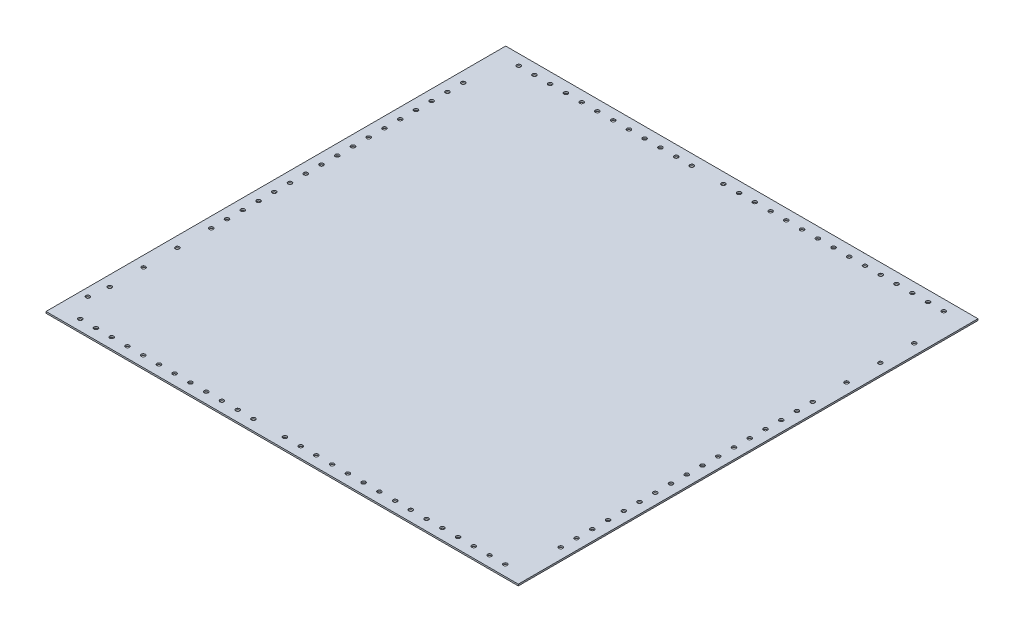
from build123d import *

# Parameters (mm, degrees)
SKETCH1_W                          = 600
SKETCH1_H                          = 584
BOSS_EXTRUDE1_DEPTH                = 2.032
F_5_0_5_DIAMETER_HOLE2_AT_2_COUNT  = 2
F_5_0_5_DIAMETER_HOLE2_AT_2_PITCH  = 724.393414567
F_5_0_5_DIAMETER_HOLE2_AT_3_COUNT  = 2
F_5_0_5_DIAMETER_HOLE2_AT_3_PITCH  = 712.134229611
F_5_0_5_DIAMETER_HOLE2_AT_4_COUNT  = 2
F_5_0_5_DIAMETER_HOLE2_AT_4_PITCH  = 700.231749422
F_5_0_5_DIAMETER_HOLE2_AT_5_COUNT  = 2
F_5_0_5_DIAMETER_HOLE2_AT_5_PITCH  = 688.704468415
F_5_0_5_DIAMETER_HOLE2_AT_6_COUNT  = 2
F_5_0_5_DIAMETER_HOLE2_AT_6_PITCH  = 677.571536245
F_5_0_5_DIAMETER_HOLE2_AT_7_COUNT  = 2
F_5_0_5_DIAMETER_HOLE2_AT_7_PITCH  = 666.85270386
F_5_0_5_DIAMETER_HOLE2_AT_8_COUNT  = 2
F_5_0_5_DIAMETER_HOLE2_AT_8_PITCH  = 656.568252781
F_5_0_5_DIAMETER_HOLE2_AT_9_COUNT  = 2
F_5_0_5_DIAMETER_HOLE2_AT_9_PITCH  = 646.738905955
F_5_0_5_DIAMETER_HOLE2_AT_10_COUNT = 2
F_5_0_5_DIAMETER_HOLE2_AT_10_PITCH = 637.385718691
F_5_0_5_DIAMETER_HOLE2_AT_11_COUNT = 2
F_5_0_5_DIAMETER_HOLE2_AT_11_PITCH = 628.529948616
F_5_0_5_DIAMETER_HOLE2_AT_12_COUNT = 2
F_5_0_5_DIAMETER_HOLE2_AT_12_PITCH = 620.192904041
F_5_0_5_DIAMETER_HOLE2_AT_13_COUNT = 2
F_5_0_5_DIAMETER_HOLE2_AT_13_PITCH = 612.395770836
F_5_0_5_DIAMETER_HOLE2_AT_14_COUNT = 2
F_5_0_5_DIAMETER_HOLE2_AT_14_PITCH = 598.504188764
F_5_0_5_DIAMETER_HOLE2_AT_15_COUNT = 2
F_5_0_5_DIAMETER_HOLE2_AT_15_PITCH = 592.449665275
F_5_0_5_DIAMETER_HOLE2_AT_16_COUNT = 2
F_5_0_5_DIAMETER_HOLE2_AT_16_PITCH = 587.014435767
F_5_0_5_DIAMETER_HOLE2_AT_17_COUNT = 2
F_5_0_5_DIAMETER_HOLE2_AT_17_PITCH = 582.21584461
F_5_0_5_DIAMETER_HOLE2_AT_18_COUNT = 2
F_5_0_5_DIAMETER_HOLE2_AT_18_PITCH = 578.069746337
F_5_0_5_DIAMETER_HOLE2_AT_19_COUNT = 2
F_5_0_5_DIAMETER_HOLE2_AT_19_PITCH = 574.590265794
F_5_0_5_DIAMETER_HOLE2_AT_20_COUNT = 2
F_5_0_5_DIAMETER_HOLE2_AT_20_PITCH = 571.789572711
F_5_0_5_DIAMETER_HOLE2_AT_21_COUNT = 2
F_5_0_5_DIAMETER_HOLE2_AT_21_PITCH = 569.677678496
F_5_0_5_DIAMETER_HOLE2_AT_22_COUNT = 2
F_5_0_5_DIAMETER_HOLE2_AT_22_PITCH = 568.262262773
F_5_0_5_DIAMETER_HOLE2_AT_23_COUNT = 2
F_5_0_5_DIAMETER_HOLE2_AT_23_PITCH = 567.548536433
F_5_0_5_DIAMETER_HOLE2_AT_24_COUNT = 2
F_5_0_5_DIAMETER_HOLE2_AT_24_PITCH = 567.539146776
F_5_0_5_DIAMETER_HOLE2_AT_25_COUNT = 2
F_5_0_5_DIAMETER_HOLE2_AT_25_PITCH = 568.234128716
F_5_0_5_DIAMETER_HOLE2_AT_26_COUNT = 2
F_5_0_5_DIAMETER_HOLE2_AT_26_PITCH = 569.630904142
F_5_0_5_DIAMETER_HOLE2_AT_27_COUNT = 2
F_5_0_5_DIAMETER_HOLE2_AT_27_PITCH = 571.724329436
F_5_0_5_DIAMETER_HOLE2_AT_28_COUNT = 2
F_5_0_5_DIAMETER_HOLE2_AT_28_PITCH = 574.506789154
F_5_0_5_DIAMETER_HOLE2_AT_29_COUNT = 2
F_5_0_5_DIAMETER_HOLE2_AT_29_PITCH = 630.477451441
F_5_0_5_DIAMETER_HOLE2_AT_30_COUNT = 2
F_5_0_5_DIAMETER_HOLE2_AT_30_PITCH = 650.2001951
F_5_0_5_DIAMETER_HOLE2_AT_31_COUNT = 2
F_5_0_5_DIAMETER_HOLE2_AT_31_PITCH = 669.939378332
F_5_0_5_DIAMETER_HOLE2_AT_32_COUNT = 2
F_5_0_5_DIAMETER_HOLE2_AT_32_PITCH = 689.693589627
F_5_0_5_DIAMETER_HOLE2_AT_33_COUNT = 2
F_5_0_5_DIAMETER_HOLE2_AT_33_PITCH = 709.461573663
F_5_0_5_DIAMETER_HOLE2_AT_34_COUNT = 2
F_5_0_5_DIAMETER_HOLE2_AT_34_PITCH = 729.242210405
F_5_0_5_DIAMETER_HOLE2_AT_35_COUNT = 2
F_5_0_5_DIAMETER_HOLE2_AT_35_PITCH = 749.034497449
F_5_0_5_DIAMETER_HOLE2_AT_36_COUNT = 2
F_5_0_5_DIAMETER_HOLE2_AT_36_PITCH = 768.83753505
F_5_0_5_DIAMETER_HOLE2_AT_37_COUNT = 2
F_5_0_5_DIAMETER_HOLE2_AT_37_PITCH = 788.650513367
F_5_0_5_DIAMETER_HOLE2_AT_38_COUNT = 2
F_5_0_5_DIAMETER_HOLE2_AT_38_PITCH = 808.472701559
F_5_0_5_DIAMETER_HOLE2_AT_39_COUNT = 2
F_5_0_5_DIAMETER_HOLE2_AT_39_PITCH = 828.30343842
F_5_0_5_DIAMETER_HOLE2_AT_40_COUNT = 2
F_5_0_5_DIAMETER_HOLE2_AT_40_PITCH = 848.142124311
F_5_0_5_DIAMETER_HOLE2_AT_41_COUNT = 2
F_5_0_5_DIAMETER_HOLE2_AT_41_PITCH = 867.988214184
F_5_0_5_DIAMETER_HOLE2_AT_42_COUNT = 2
F_5_0_5_DIAMETER_HOLE2_AT_42_PITCH = 887.841211532
F_5_0_5_DIAMETER_HOLE2_AT_43_COUNT = 2
F_5_0_5_DIAMETER_HOLE2_AT_43_PITCH = 907.700663119
F_5_0_5_DIAMETER_HOLE2_AT_44_COUNT = 2
F_5_0_5_DIAMETER_HOLE2_AT_44_PITCH = 927.566154384
F_5_0_5_DIAMETER_HOLE2_AT_45_COUNT = 2
F_5_0_5_DIAMETER_HOLE2_AT_45_PITCH = 947.437305415
F_5_0_5_DIAMETER_HOLE2_AT_46_COUNT = 2
F_5_0_5_DIAMETER_HOLE2_AT_46_PITCH = 990.177849225
F_5_0_5_DIAMETER_HOLE2_AT_47_COUNT = 2
F_5_0_5_DIAMETER_HOLE2_AT_47_PITCH = 1032.939929764
F_5_0_5_DIAMETER_HOLE2_AT_48_COUNT = 2
F_5_0_5_DIAMETER_HOLE2_AT_48_PITCH = 1075.720978649
F_5_0_5_DIAMETER_HOLE2_AT_49_COUNT = 2
F_5_0_5_DIAMETER_HOLE2_AT_49_PITCH = 1128.042899183
F_5_0_5_DIAMETER_HOLE2_AT_50_COUNT = 2
F_5_0_5_DIAMETER_HOLE2_AT_50_PITCH = 1126.628350647
F_5_0_5_DIAMETER_HOLE2_AT_51_COUNT = 2
F_5_0_5_DIAMETER_HOLE2_AT_51_PITCH = 1125.567456248
F_5_0_5_DIAMETER_HOLE2_AT_52_COUNT = 2
F_5_0_5_DIAMETER_HOLE2_AT_52_PITCH = 1124.861216618
F_5_0_5_DIAMETER_HOLE2_AT_53_COUNT = 2
F_5_0_5_DIAMETER_HOLE2_AT_53_PITCH = 1124.510299968
F_5_0_5_DIAMETER_HOLE2_AT_54_COUNT = 2
F_5_0_5_DIAMETER_HOLE2_AT_54_PITCH = 1124.515038948
F_5_0_5_DIAMETER_HOLE2_AT_55_COUNT = 2
F_5_0_5_DIAMETER_HOLE2_AT_55_PITCH = 1124.87542906
F_5_0_5_DIAMETER_HOLE2_AT_56_COUNT = 2
F_5_0_5_DIAMETER_HOLE2_AT_56_PITCH = 1126.661460721
F_5_0_5_DIAMETER_HOLE2_AT_57_COUNT = 2
F_5_0_5_DIAMETER_HOLE2_AT_57_PITCH = 1125.591128691
F_5_0_5_DIAMETER_HOLE2_AT_58_COUNT = 2
F_5_0_5_DIAMETER_HOLE2_AT_58_PITCH = 1128.085415719
F_5_0_5_DIAMETER_HOLE2_AT_59_COUNT = 2
F_5_0_5_DIAMETER_HOLE2_AT_59_PITCH = 1129.861656683
F_5_0_5_DIAMETER_HOLE2_AT_60_COUNT = 2
F_5_0_5_DIAMETER_HOLE2_AT_60_PITCH = 1131.988525263
F_5_0_5_DIAMETER_HOLE2_AT_61_COUNT = 2
F_5_0_5_DIAMETER_HOLE2_AT_61_PITCH = 1134.464049413
F_5_0_5_DIAMETER_HOLE2_AT_62_COUNT = 2
F_5_0_5_DIAMETER_HOLE2_AT_62_PITCH = 1137.285952387
F_5_0_5_DIAMETER_HOLE2_AT_63_COUNT = 2
F_5_0_5_DIAMETER_HOLE2_AT_63_PITCH = 1140.451662974
F_5_0_5_DIAMETER_HOLE2_AT_64_COUNT = 2
F_5_0_5_DIAMETER_HOLE2_AT_64_PITCH = 1147.802819194
F_5_0_5_DIAMETER_HOLE2_AT_65_COUNT = 2
F_5_0_5_DIAMETER_HOLE2_AT_65_PITCH = 1156.491516579
F_5_0_5_DIAMETER_HOLE2_AT_66_COUNT = 2
F_5_0_5_DIAMETER_HOLE2_AT_66_PITCH = 1151.981757596
F_5_0_5_DIAMETER_HOLE2_AT_67_COUNT = 2
F_5_0_5_DIAMETER_HOLE2_AT_67_PITCH = 1161.328242145
F_5_0_5_DIAMETER_HOLE2_AT_68_COUNT = 2
F_5_0_5_DIAMETER_HOLE2_AT_68_PITCH = 1166.487867098
F_5_0_5_DIAMETER_HOLE2_AT_69_COUNT = 2
F_5_0_5_DIAMETER_HOLE2_AT_69_PITCH = 1171.966126717
F_5_0_5_DIAMETER_HOLE2_AT_70_COUNT = 2
F_5_0_5_DIAMETER_HOLE2_AT_70_PITCH = 1177.758574691
F_5_0_5_DIAMETER_HOLE2_AT_71_COUNT = 2
F_5_0_5_DIAMETER_HOLE2_AT_71_PITCH = 1183.860599201
F_5_0_5_DIAMETER_HOLE2_AT_72_COUNT = 2
F_5_0_5_DIAMETER_HOLE2_AT_72_PITCH = 1190.267439035
F_5_0_5_DIAMETER_HOLE2_AT_73_COUNT = 2
F_5_0_5_DIAMETER_HOLE2_AT_73_PITCH = 1196.974199601
F_5_0_5_DIAMETER_HOLE2_AT_74_COUNT = 2
F_5_0_5_DIAMETER_HOLE2_AT_74_PITCH = 1203.975868776
F_5_0_5_DIAMETER_HOLE2_AT_75_COUNT = 2
F_5_0_5_DIAMETER_HOLE2_AT_75_PITCH = 1211.267332458
F_5_0_5_DIAMETER_HOLE3_AT_2_COUNT  = 2
F_5_0_5_DIAMETER_HOLE3_AT_2_PITCH  = 20
F_5_0_5_DIAMETER_HOLE3_AT_3_COUNT  = 2
F_5_0_5_DIAMETER_HOLE3_AT_3_PITCH  = 40
F_5_0_5_DIAMETER_HOLE3_AT_4_COUNT  = 2
F_5_0_5_DIAMETER_HOLE3_AT_4_PITCH  = 60
F_5_0_5_DIAMETER_HOLE3_AT_5_COUNT  = 2
F_5_0_5_DIAMETER_HOLE3_AT_5_PITCH  = 80
F_5_0_5_DIAMETER_HOLE3_AT_6_COUNT  = 2
F_5_0_5_DIAMETER_HOLE3_AT_6_PITCH  = 100
F_5_0_5_DIAMETER_HOLE3_AT_7_COUNT  = 2
F_5_0_5_DIAMETER_HOLE3_AT_7_PITCH  = 120
F_5_0_5_DIAMETER_HOLE3_AT_8_COUNT  = 2
F_5_0_5_DIAMETER_HOLE3_AT_8_PITCH  = 140
F_5_0_5_DIAMETER_HOLE3_AT_9_COUNT  = 2
F_5_0_5_DIAMETER_HOLE3_AT_9_PITCH  = 160
F_5_0_5_DIAMETER_HOLE3_AT_10_COUNT = 2
F_5_0_5_DIAMETER_HOLE3_AT_10_PITCH = 180
F_5_0_5_DIAMETER_HOLE3_AT_11_COUNT = 2
F_5_0_5_DIAMETER_HOLE3_AT_11_PITCH = 200
F_5_0_5_DIAMETER_HOLE3_AT_12_COUNT = 2
F_5_0_5_DIAMETER_HOLE3_AT_12_PITCH = 220
F_5_0_5_DIAMETER_HOLE3_AT_13_COUNT = 2
F_5_0_5_DIAMETER_HOLE3_AT_13_PITCH = 240
F_5_0_5_DIAMETER_HOLE3_AT_14_COUNT = 2
F_5_0_5_DIAMETER_HOLE3_AT_14_PITCH = 260
F_5_0_5_DIAMETER_HOLE3_AT_15_COUNT = 2
F_5_0_5_DIAMETER_HOLE3_AT_15_PITCH = 280
F_5_0_5_DIAMETER_HOLE3_AT_16_COUNT = 2
F_5_0_5_DIAMETER_HOLE3_AT_16_PITCH = 300
F_5_0_5_DIAMETER_HOLE3_AT_17_COUNT = 2
F_5_0_5_DIAMETER_HOLE3_AT_17_PITCH = 320
F_5_0_5_DIAMETER_HOLE3_AT_18_COUNT = 2
F_5_0_5_DIAMETER_HOLE3_AT_18_PITCH = 363
F_5_0_5_DIAMETER_HOLE3_AT_19_COUNT = 2
F_5_0_5_DIAMETER_HOLE3_AT_19_PITCH = 406
F_5_0_5_DIAMETER_HOLE3_AT_20_COUNT = 2
F_5_0_5_DIAMETER_HOLE3_AT_20_PITCH = 449
F_5_0_5_DIAMETER_HOLE3_AT_21_COUNT = 2
F_5_0_5_DIAMETER_HOLE3_AT_21_PITCH = 473.647761944


with BuildPart() as part:
    # Sketch1 → Boss-Extrude1 (new body)
    with BuildSketch(Plane(origin=(0, 0, 0), x_dir=(1, 0, 0), z_dir=(0, 1, 0))):
        with Locations((300, 292)):
            Rectangle(SKETCH1_W, SKETCH1_H)
    extrude(amount=BOSS_EXTRUDE1_DEPTH)

    # Sketch2 → Ø5.0 (5) Diameter Hole2 (revolve, cut)
    with BuildSketch(Plane(origin=(480.266452114, 2.032, 553.961923307), x_dir=(0, 0, 1), z_dir=(1, 0, 0))):
        Polygon((0, 0), (0, 2.032), (2.5, 2.032), (2.5, 0.020977491), (2.525, 0), align=None)
    f_5_0_5_diameter_hole2 = revolve(axis=Axis((480.266452114, 8.382, 553.961923307), (0, -1, 0)), mode=Mode.SUBTRACT)

    # Ø5.0 (5) Diameter Hole2 at 2: Ø5.0 (5) Diameter Hole2 ×2
    with Locations(*[Vector(-0.62157723, 0, -0.783352888) * (i * F_5_0_5_DIAMETER_HOLE2_AT_2_PITCH) for i in range(1, F_5_0_5_DIAMETER_HOLE2_AT_2_COUNT)]):
        add(f_5_0_5_diameter_hole2, mode=Mode.SUBTRACT)

    # Ø5.0 (5) Diameter Hole2 at 3: Ø5.0 (5) Diameter Hole2 ×2
    with Locations(*[Vector(-0.604192909, 0, -0.796838082) * (i * F_5_0_5_DIAMETER_HOLE2_AT_3_PITCH) for i in range(1, F_5_0_5_DIAMETER_HOLE2_AT_3_COUNT)]):
        add(f_5_0_5_diameter_hole2, mode=Mode.SUBTRACT)

    # Ø5.0 (5) Diameter Hole2 at 4: Ø5.0 (5) Diameter Hole2 ×2
    with Locations(*[Vector(-0.585900957, 0, -0.810382668) * (i * F_5_0_5_DIAMETER_HOLE2_AT_4_PITCH) for i in range(1, F_5_0_5_DIAMETER_HOLE2_AT_4_COUNT)]):
        add(f_5_0_5_diameter_hole2, mode=Mode.SUBTRACT)

    # Ø5.0 (5) Diameter Hole2 at 5: Ø5.0 (5) Diameter Hole2 ×2
    with Locations(*[Vector(-0.566667519, 0, -0.823946554) * (i * F_5_0_5_DIAMETER_HOLE2_AT_5_PITCH) for i in range(1, F_5_0_5_DIAMETER_HOLE2_AT_5_COUNT)]):
        add(f_5_0_5_diameter_hole2, mode=Mode.SUBTRACT)

    # Ø5.0 (5) Diameter Hole2 at 6: Ø5.0 (5) Diameter Hole2 ×2
    with Locations(*[Vector(-0.546461048, 0, -0.837484521) * (i * F_5_0_5_DIAMETER_HOLE2_AT_6_PITCH) for i in range(1, F_5_0_5_DIAMETER_HOLE2_AT_6_COUNT)]):
        add(f_5_0_5_diameter_hole2, mode=Mode.SUBTRACT)

    # Ø5.0 (5) Diameter Hole2 at 7: Ø5.0 (5) Diameter Hole2 ×2
    with Locations(*[Vector(-0.525253103, 0, -0.850946049) * (i * F_5_0_5_DIAMETER_HOLE2_AT_7_PITCH) for i in range(1, F_5_0_5_DIAMETER_HOLE2_AT_7_COUNT)]):
        add(f_5_0_5_diameter_hole2, mode=Mode.SUBTRACT)

    # Ø5.0 (5) Diameter Hole2 at 8: Ø5.0 (5) Diameter Hole2 ×2
    with Locations(*[Vector(-0.503019223, 0, -0.864275223) * (i * F_5_0_5_DIAMETER_HOLE2_AT_8_PITCH) for i in range(1, F_5_0_5_DIAMETER_HOLE2_AT_8_COUNT)]):
        add(f_5_0_5_diameter_hole2, mode=Mode.SUBTRACT)

    # Ø5.0 (5) Diameter Hole2 at 9: Ø5.0 (5) Diameter Hole2 ×2
    with Locations(*[Vector(-0.479739891, 0, -0.877410757) * (i * F_5_0_5_DIAMETER_HOLE2_AT_9_PITCH) for i in range(1, F_5_0_5_DIAMETER_HOLE2_AT_9_COUNT)]):
        add(f_5_0_5_diameter_hole2, mode=Mode.SUBTRACT)

    # Ø5.0 (5) Diameter Hole2 at 10: Ø5.0 (5) Diameter Hole2 ×2
    with Locations(*[Vector(-0.455401562, 0, -0.890286143) * (i * F_5_0_5_DIAMETER_HOLE2_AT_10_PITCH) for i in range(1, F_5_0_5_DIAMETER_HOLE2_AT_10_COUNT)]):
        add(f_5_0_5_diameter_hole2, mode=Mode.SUBTRACT)

    # Ø5.0 (5) Diameter Hole2 at 11: Ø5.0 (5) Diameter Hole2 ×2
    with Locations(*[Vector(-0.429997732, 0, -0.902829968) * (i * F_5_0_5_DIAMETER_HOLE2_AT_11_PITCH) for i in range(1, F_5_0_5_DIAMETER_HOLE2_AT_11_COUNT)]):
        add(f_5_0_5_diameter_hole2, mode=Mode.SUBTRACT)

    # Ø5.0 (5) Diameter Hole2 at 12: Ø5.0 (5) Diameter Hole2 ×2
    with Locations(*[Vector(-0.403530015, 0, -0.914966407) * (i * F_5_0_5_DIAMETER_HOLE2_AT_12_PITCH) for i in range(1, F_5_0_5_DIAMETER_HOLE2_AT_12_COUNT)]):
        add(f_5_0_5_diameter_hole2, mode=Mode.SUBTRACT)

    # Ø5.0 (5) Diameter Hole2 at 13: Ø5.0 (5) Diameter Hole2 ×2
    with Locations(*[Vector(-0.376009213, 0, -0.926615924) * (i * F_5_0_5_DIAMETER_HOLE2_AT_13_PITCH) for i in range(1, F_5_0_5_DIAMETER_HOLE2_AT_13_COUNT)]):
        add(f_5_0_5_diameter_hole2, mode=Mode.SUBTRACT)

    # Ø5.0 (5) Diameter Hole2 at 14: Ø5.0 (5) Diameter Hole2 ×2
    with Locations(*[Vector(-0.317903292, 0, -0.948123144) * (i * F_5_0_5_DIAMETER_HOLE2_AT_14_PITCH) for i in range(1, F_5_0_5_DIAMETER_HOLE2_AT_14_COUNT)]):
        add(f_5_0_5_diameter_hole2, mode=Mode.SUBTRACT)

    # Ø5.0 (5) Diameter Hole2 at 15: Ø5.0 (5) Diameter Hole2 ×2
    with Locations(*[Vector(-0.287393954, 0, -0.957812463) * (i * F_5_0_5_DIAMETER_HOLE2_AT_15_PITCH) for i in range(1, F_5_0_5_DIAMETER_HOLE2_AT_15_COUNT)]):
        add(f_5_0_5_diameter_hole2, mode=Mode.SUBTRACT)

    # Ø5.0 (5) Diameter Hole2 at 16: Ø5.0 (5) Diameter Hole2 ×2
    with Locations(*[Vector(-0.255984253, 0, -0.966680951) * (i * F_5_0_5_DIAMETER_HOLE2_AT_16_PITCH) for i in range(1, F_5_0_5_DIAMETER_HOLE2_AT_16_COUNT)]):
        add(f_5_0_5_diameter_hole2, mode=Mode.SUBTRACT)

    # Ø5.0 (5) Diameter Hole2 at 17: Ø5.0 (5) Diameter Hole2 ×2
    with Locations(*[Vector(-0.22374254, 0, -0.974648283) * (i * F_5_0_5_DIAMETER_HOLE2_AT_17_PITCH) for i in range(1, F_5_0_5_DIAMETER_HOLE2_AT_17_COUNT)]):
        add(f_5_0_5_diameter_hole2, mode=Mode.SUBTRACT)

    # Ø5.0 (5) Diameter Hole2 at 18: Ø5.0 (5) Diameter Hole2 ×2
    with Locations(*[Vector(-0.190749391, 0, -0.981638767) * (i * F_5_0_5_DIAMETER_HOLE2_AT_18_PITCH) for i in range(1, F_5_0_5_DIAMETER_HOLE2_AT_18_COUNT)]):
        add(f_5_0_5_diameter_hole2, mode=Mode.SUBTRACT)

    # Ø5.0 (5) Diameter Hole2 at 19: Ø5.0 (5) Diameter Hole2 ×2
    with Locations(*[Vector(-0.157097079, 0, -0.987583165) * (i * F_5_0_5_DIAMETER_HOLE2_AT_19_PITCH) for i in range(1, F_5_0_5_DIAMETER_HOLE2_AT_19_COUNT)]):
        add(f_5_0_5_diameter_hole2, mode=Mode.SUBTRACT)

    # Ø5.0 (5) Diameter Hole2 at 20: Ø5.0 (5) Diameter Hole2 ×2
    with Locations(*[Vector(-0.122888656, 0, -0.992420464) * (i * F_5_0_5_DIAMETER_HOLE2_AT_20_PITCH) for i in range(1, F_5_0_5_DIAMETER_HOLE2_AT_20_COUNT)]):
        add(f_5_0_5_diameter_hole2, mode=Mode.SUBTRACT)

    # Ø5.0 (5) Diameter Hole2 at 21: Ø5.0 (5) Diameter Hole2 ×2
    with Locations(*[Vector(-0.088236654, 0, -0.99609954) * (i * F_5_0_5_DIAMETER_HOLE2_AT_21_PITCH) for i in range(1, F_5_0_5_DIAMETER_HOLE2_AT_21_COUNT)]):
        add(f_5_0_5_diameter_hole2, mode=Mode.SUBTRACT)

    # Ø5.0 (5) Diameter Hole2 at 22: Ø5.0 (5) Diameter Hole2 ×2
    with Locations(*[Vector(-0.053261415, 0, -0.998580604) * (i * F_5_0_5_DIAMETER_HOLE2_AT_22_PITCH) for i in range(1, F_5_0_5_DIAMETER_HOLE2_AT_22_COUNT)]):
        add(f_5_0_5_diameter_hole2, mode=Mode.SUBTRACT)

    # Ø5.0 (5) Diameter Hole2 at 23: Ø5.0 (5) Diameter Hole2 ×2
    with Locations(*[Vector(-0.018089117, 0, -0.999836379) * (i * F_5_0_5_DIAMETER_HOLE2_AT_23_PITCH) for i in range(1, F_5_0_5_DIAMETER_HOLE2_AT_23_COUNT)]):
        add(f_5_0_5_diameter_hole2, mode=Mode.SUBTRACT)

    # Ø5.0 (5) Diameter Hole2 at 24: Ø5.0 (5) Diameter Hole2 ×2
    with Locations(*[Vector(0.017150443, 0, -0.99985292) * (i * F_5_0_5_DIAMETER_HOLE2_AT_24_PITCH) for i in range(1, F_5_0_5_DIAMETER_HOLE2_AT_24_COUNT)]):
        add(f_5_0_5_diameter_hole2, mode=Mode.SUBTRACT)

    # Ø5.0 (5) Diameter Hole2 at 25: Ø5.0 (5) Diameter Hole2 ×2
    with Locations(*[Vector(0.052326227, 0, -0.998630045) * (i * F_5_0_5_DIAMETER_HOLE2_AT_25_PITCH) for i in range(1, F_5_0_5_DIAMETER_HOLE2_AT_25_COUNT)]):
        add(f_5_0_5_diameter_hole2, mode=Mode.SUBTRACT)

    # Ø5.0 (5) Diameter Hole2 at 26: Ø5.0 (5) Diameter Hole2 ×2
    with Locations(*[Vector(0.087308374, 0, -0.996181333) * (i * F_5_0_5_DIAMETER_HOLE2_AT_26_PITCH) for i in range(1, F_5_0_5_DIAMETER_HOLE2_AT_26_COUNT)]):
        add(f_5_0_5_diameter_hole2, mode=Mode.SUBTRACT)

    # Ø5.0 (5) Diameter Hole2 at 27: Ø5.0 (5) Diameter Hole2 ×2
    with Locations(*[Vector(0.12197058, 0, -0.992533716) * (i * F_5_0_5_DIAMETER_HOLE2_AT_27_PITCH) for i in range(1, F_5_0_5_DIAMETER_HOLE2_AT_27_COUNT)]):
        add(f_5_0_5_diameter_hole2, mode=Mode.SUBTRACT)

    # Ø5.0 (5) Diameter Hole2 at 28: Ø5.0 (5) Diameter Hole2 ×2
    with Locations(*[Vector(0.156192319, 0, -0.987726662) * (i * F_5_0_5_DIAMETER_HOLE2_AT_28_PITCH) for i in range(1, F_5_0_5_DIAMETER_HOLE2_AT_28_COUNT)]):
        add(f_5_0_5_diameter_hole2, mode=Mode.SUBTRACT)

    # Ø5.0 (5) Diameter Hole2 at 29: Ø5.0 (5) Diameter Hole2 ×2
    with Locations(*[Vector(0.168506895, 0, -0.985700475) * (i * F_5_0_5_DIAMETER_HOLE2_AT_29_PITCH) for i in range(1, F_5_0_5_DIAMETER_HOLE2_AT_29_COUNT)]):
        add(f_5_0_5_diameter_hole2, mode=Mode.SUBTRACT)

    # Ø5.0 (5) Diameter Hole2 at 30: Ø5.0 (5) Diameter Hole2 ×2
    with Locations(*[Vector(0.163395518, 0, -0.986560644) * (i * F_5_0_5_DIAMETER_HOLE2_AT_30_PITCH) for i in range(1, F_5_0_5_DIAMETER_HOLE2_AT_30_COUNT)]):
        add(f_5_0_5_diameter_hole2, mode=Mode.SUBTRACT)

    # Ø5.0 (5) Diameter Hole2 at 31: Ø5.0 (5) Diameter Hole2 ×2
    with Locations(*[Vector(0.158581211, 0, -0.987345937) * (i * F_5_0_5_DIAMETER_HOLE2_AT_31_PITCH) for i in range(1, F_5_0_5_DIAMETER_HOLE2_AT_31_COUNT)]):
        add(f_5_0_5_diameter_hole2, mode=Mode.SUBTRACT)

    # Ø5.0 (5) Diameter Hole2 at 32: Ø5.0 (5) Diameter Hole2 ×2
    with Locations(*[Vector(0.154039126, 0, -0.988064749) * (i * F_5_0_5_DIAMETER_HOLE2_AT_32_PITCH) for i in range(1, F_5_0_5_DIAMETER_HOLE2_AT_32_COUNT)]):
        add(f_5_0_5_diameter_hole2, mode=Mode.SUBTRACT)

    # Ø5.0 (5) Diameter Hole2 at 33: Ø5.0 (5) Diameter Hole2 ×2
    with Locations(*[Vector(0.149747078, 0, -0.988724336) * (i * F_5_0_5_DIAMETER_HOLE2_AT_33_PITCH) for i in range(1, F_5_0_5_DIAMETER_HOLE2_AT_33_COUNT)]):
        add(f_5_0_5_diameter_hole2, mode=Mode.SUBTRACT)

    # Ø5.0 (5) Diameter Hole2 at 34: Ø5.0 (5) Diameter Hole2 ×2
    with Locations(*[Vector(0.145685201, 0, -0.989330997) * (i * F_5_0_5_DIAMETER_HOLE2_AT_34_PITCH) for i in range(1, F_5_0_5_DIAMETER_HOLE2_AT_34_COUNT)]):
        add(f_5_0_5_diameter_hole2, mode=Mode.SUBTRACT)

    # Ø5.0 (5) Diameter Hole2 at 35: Ø5.0 (5) Diameter Hole2 ×2
    with Locations(*[Vector(0.141835654, 0, -0.98989022) * (i * F_5_0_5_DIAMETER_HOLE2_AT_35_PITCH) for i in range(1, F_5_0_5_DIAMETER_HOLE2_AT_35_COUNT)]):
        add(f_5_0_5_diameter_hole2, mode=Mode.SUBTRACT)

    # Ø5.0 (5) Diameter Hole2 at 36: Ø5.0 (5) Diameter Hole2 ×2
    with Locations(*[Vector(0.138182377, 0, -0.990406801) * (i * F_5_0_5_DIAMETER_HOLE2_AT_36_PITCH) for i in range(1, F_5_0_5_DIAMETER_HOLE2_AT_36_COUNT)]):
        add(f_5_0_5_diameter_hole2, mode=Mode.SUBTRACT)

    # Ø5.0 (5) Diameter Hole2 at 37: Ø5.0 (5) Diameter Hole2 ×2
    with Locations(*[Vector(0.134710871, 0, -0.990884948) * (i * F_5_0_5_DIAMETER_HOLE2_AT_37_PITCH) for i in range(1, F_5_0_5_DIAMETER_HOLE2_AT_37_COUNT)]):
        add(f_5_0_5_diameter_hole2, mode=Mode.SUBTRACT)

    # Ø5.0 (5) Diameter Hole2 at 38: Ø5.0 (5) Diameter Hole2 ×2
    with Locations(*[Vector(0.131408021, 0, -0.991328367) * (i * F_5_0_5_DIAMETER_HOLE2_AT_38_PITCH) for i in range(1, F_5_0_5_DIAMETER_HOLE2_AT_38_COUNT)]):
        add(f_5_0_5_diameter_hole2, mode=Mode.SUBTRACT)

    # Ø5.0 (5) Diameter Hole2 at 39: Ø5.0 (5) Diameter Hole2 ×2
    with Locations(*[Vector(0.12826193, 0, -0.991740328) * (i * F_5_0_5_DIAMETER_HOLE2_AT_39_PITCH) for i in range(1, F_5_0_5_DIAMETER_HOLE2_AT_39_COUNT)]):
        add(f_5_0_5_diameter_hole2, mode=Mode.SUBTRACT)

    # Ø5.0 (5) Diameter Hole2 at 40: Ø5.0 (5) Diameter Hole2 ×2
    with Locations(*[Vector(0.125261787, 0, -0.992123725) * (i * F_5_0_5_DIAMETER_HOLE2_AT_40_PITCH) for i in range(1, F_5_0_5_DIAMETER_HOLE2_AT_40_COUNT)]):
        add(f_5_0_5_diameter_hole2, mode=Mode.SUBTRACT)

    # Ø5.0 (5) Diameter Hole2 at 41: Ø5.0 (5) Diameter Hole2 ×2
    with Locations(*[Vector(0.122397742, 0, -0.99248113) * (i * F_5_0_5_DIAMETER_HOLE2_AT_41_PITCH) for i in range(1, F_5_0_5_DIAMETER_HOLE2_AT_41_COUNT)]):
        add(f_5_0_5_diameter_hole2, mode=Mode.SUBTRACT)

    # Ø5.0 (5) Diameter Hole2 at 42: Ø5.0 (5) Diameter Hole2 ×2
    with Locations(*[Vector(0.119660809, 0, -0.992814832) * (i * F_5_0_5_DIAMETER_HOLE2_AT_42_PITCH) for i in range(1, F_5_0_5_DIAMETER_HOLE2_AT_42_COUNT)]):
        add(f_5_0_5_diameter_hole2, mode=Mode.SUBTRACT)

    # Ø5.0 (5) Diameter Hole2 at 43: Ø5.0 (5) Diameter Hole2 ×2
    with Locations(*[Vector(0.117042768, 0, -0.993126875) * (i * F_5_0_5_DIAMETER_HOLE2_AT_43_PITCH) for i in range(1, F_5_0_5_DIAMETER_HOLE2_AT_43_COUNT)]):
        add(f_5_0_5_diameter_hole2, mode=Mode.SUBTRACT)

    # Ø5.0 (5) Diameter Hole2 at 44: Ø5.0 (5) Diameter Hole2 ×2
    with Locations(*[Vector(0.114536087, 0, -0.993419088) * (i * F_5_0_5_DIAMETER_HOLE2_AT_44_PITCH) for i in range(1, F_5_0_5_DIAMETER_HOLE2_AT_44_COUNT)]):
        add(f_5_0_5_diameter_hole2, mode=Mode.SUBTRACT)

    # Ø5.0 (5) Diameter Hole2 at 45: Ø5.0 (5) Diameter Hole2 ×2
    with Locations(*[Vector(0.112133855, 0, -0.993693111) * (i * F_5_0_5_DIAMETER_HOLE2_AT_45_PITCH) for i in range(1, F_5_0_5_DIAMETER_HOLE2_AT_45_COUNT)]):
        add(f_5_0_5_diameter_hole2, mode=Mode.SUBTRACT)

    # Ø5.0 (5) Diameter Hole2 at 46: Ø5.0 (5) Diameter Hole2 ×2
    with Locations(*[Vector(0.107293652, 0, -0.994227374) * (i * F_5_0_5_DIAMETER_HOLE2_AT_46_PITCH) for i in range(1, F_5_0_5_DIAMETER_HOLE2_AT_46_COUNT)]):
        add(f_5_0_5_diameter_hole2, mode=Mode.SUBTRACT)

    # Ø5.0 (5) Diameter Hole2 at 47: Ø5.0 (5) Diameter Hole2 ×2
    with Locations(*[Vector(0.102851865, 0, -0.994696684) * (i * F_5_0_5_DIAMETER_HOLE2_AT_47_PITCH) for i in range(1, F_5_0_5_DIAMETER_HOLE2_AT_47_COUNT)]):
        add(f_5_0_5_diameter_hole2, mode=Mode.SUBTRACT)

    # Ø5.0 (5) Diameter Hole2 at 48: Ø5.0 (5) Diameter Hole2 ×2
    with Locations(*[Vector(0.098761482, 0, -0.995111134) * (i * F_5_0_5_DIAMETER_HOLE2_AT_48_PITCH) for i in range(1, F_5_0_5_DIAMETER_HOLE2_AT_48_COUNT)]):
        add(f_5_0_5_diameter_hole2, mode=Mode.SUBTRACT)

    # Ø5.0 (5) Diameter Hole2 at 49: Ø5.0 (5) Diameter Hole2 ×2
    with Locations(*[Vector(0.079547992, 0, -0.996831037) * (i * F_5_0_5_DIAMETER_HOLE2_AT_49_PITCH) for i in range(1, F_5_0_5_DIAMETER_HOLE2_AT_49_COUNT)]):
        add(f_5_0_5_diameter_hole2, mode=Mode.SUBTRACT)

    # Ø5.0 (5) Diameter Hole2 at 50: Ø5.0 (5) Diameter Hole2 ×2
    with Locations(*[Vector(0.061895787, 0, -0.998082618) * (i * F_5_0_5_DIAMETER_HOLE2_AT_50_PITCH) for i in range(1, F_5_0_5_DIAMETER_HOLE2_AT_50_COUNT)]):
        add(f_5_0_5_diameter_hole2, mode=Mode.SUBTRACT)

    # Ø5.0 (5) Diameter Hole2 at 51: Ø5.0 (5) Diameter Hole2 ×2
    with Locations(*[Vector(0.044185311, 0, -0.999023352) * (i * F_5_0_5_DIAMETER_HOLE2_AT_51_PITCH) for i in range(1, F_5_0_5_DIAMETER_HOLE2_AT_51_COUNT)]):
        add(f_5_0_5_diameter_hole2, mode=Mode.SUBTRACT)

    # Ø5.0 (5) Diameter Hole2 at 52: Ø5.0 (5) Diameter Hole2 ×2
    with Locations(*[Vector(0.026433081, 0, -0.999650585) * (i * F_5_0_5_DIAMETER_HOLE2_AT_52_PITCH) for i in range(1, F_5_0_5_DIAMETER_HOLE2_AT_52_COUNT)]):
        add(f_5_0_5_diameter_hole2, mode=Mode.SUBTRACT)

    # Ø5.0 (5) Diameter Hole2 at 53: Ø5.0 (5) Diameter Hole2 ×2
    with Locations(*[Vector(0.00865581, 0, -0.999962538) * (i * F_5_0_5_DIAMETER_HOLE2_AT_53_PITCH) for i in range(1, F_5_0_5_DIAMETER_HOLE2_AT_53_COUNT)]):
        add(f_5_0_5_diameter_hole2, mode=Mode.SUBTRACT)

    # Ø5.0 (5) Diameter Hole2 at 54: Ø5.0 (5) Diameter Hole2 ×2
    with Locations(*[Vector(-0.009129671, 0, -0.999958324) * (i * F_5_0_5_DIAMETER_HOLE2_AT_54_PITCH) for i in range(1, F_5_0_5_DIAMETER_HOLE2_AT_54_COUNT)]):
        add(f_5_0_5_diameter_hole2, mode=Mode.SUBTRACT)

    # Ø5.0 (5) Diameter Hole2 at 55: Ø5.0 (5) Diameter Hole2 ×2
    with Locations(*[Vector(-0.026906492, 0, -0.999637955) * (i * F_5_0_5_DIAMETER_HOLE2_AT_55_PITCH) for i in range(1, F_5_0_5_DIAMETER_HOLE2_AT_55_COUNT)]):
        add(f_5_0_5_diameter_hole2, mode=Mode.SUBTRACT)

    # Ø5.0 (5) Diameter Hole2 at 56: Ø5.0 (5) Diameter Hole2 ×2
    with Locations(*[Vector(-0.062366962, 0, -0.998053286) * (i * F_5_0_5_DIAMETER_HOLE2_AT_56_PITCH) for i in range(1, F_5_0_5_DIAMETER_HOLE2_AT_56_COUNT)]):
        add(f_5_0_5_diameter_hole2, mode=Mode.SUBTRACT)

    # Ø5.0 (5) Diameter Hole2 at 57: Ø5.0 (5) Diameter Hole2 ×2
    with Locations(*[Vector(-0.044657825, 0, -0.999002342) * (i * F_5_0_5_DIAMETER_HOLE2_AT_57_PITCH) for i in range(1, F_5_0_5_DIAMETER_HOLE2_AT_57_COUNT)]):
        add(f_5_0_5_diameter_hole2, mode=Mode.SUBTRACT)

    # Ø5.0 (5) Diameter Hole2 at 58: Ø5.0 (5) Diameter Hole2 ×2
    with Locations(*[Vector(-0.080017391, 0, -0.996793468) * (i * F_5_0_5_DIAMETER_HOLE2_AT_58_PITCH) for i in range(1, F_5_0_5_DIAMETER_HOLE2_AT_58_COUNT)]):
        add(f_5_0_5_diameter_hole2, mode=Mode.SUBTRACT)

    # Ø5.0 (5) Diameter Hole2 at 59: Ø5.0 (5) Diameter Hole2 ×2
    with Locations(*[Vector(-0.097592879, 0, -0.995226421) * (i * F_5_0_5_DIAMETER_HOLE2_AT_59_PITCH) for i in range(1, F_5_0_5_DIAMETER_HOLE2_AT_59_COUNT)]):
        add(f_5_0_5_diameter_hole2, mode=Mode.SUBTRACT)

    # Ø5.0 (5) Diameter Hole2 at 60: Ø5.0 (5) Diameter Hole2 ×2
    with Locations(*[Vector(-0.115077538, 0, -0.993356512) * (i * F_5_0_5_DIAMETER_HOLE2_AT_60_PITCH) for i in range(1, F_5_0_5_DIAMETER_HOLE2_AT_60_COUNT)]):
        add(f_5_0_5_diameter_hole2, mode=Mode.SUBTRACT)

    # Ø5.0 (5) Diameter Hole2 at 61: Ø5.0 (5) Diameter Hole2 ×2
    with Locations(*[Vector(-0.132455896, 0, -0.9911889) * (i * F_5_0_5_DIAMETER_HOLE2_AT_61_PITCH) for i in range(1, F_5_0_5_DIAMETER_HOLE2_AT_61_COUNT)]):
        add(f_5_0_5_diameter_hole2, mode=Mode.SUBTRACT)

    # Ø5.0 (5) Diameter Hole2 at 62: Ø5.0 (5) Diameter Hole2 ×2
    with Locations(*[Vector(-0.149712965, 0, -0.988729502) * (i * F_5_0_5_DIAMETER_HOLE2_AT_62_PITCH) for i in range(1, F_5_0_5_DIAMETER_HOLE2_AT_62_COUNT)]):
        add(f_5_0_5_diameter_hole2, mode=Mode.SUBTRACT)

    # Ø5.0 (5) Diameter Hole2 at 63: Ø5.0 (5) Diameter Hole2 ×2
    with Locations(*[Vector(-0.166834298, 0, -0.985984948) * (i * F_5_0_5_DIAMETER_HOLE2_AT_63_PITCH) for i in range(1, F_5_0_5_DIAMETER_HOLE2_AT_63_COUNT)]):
        add(f_5_0_5_diameter_hole2, mode=Mode.SUBTRACT)

    # Ø5.0 (5) Diameter Hole2 at 64: Ø5.0 (5) Diameter Hole2 ×2
    with Locations(*[Vector(-0.200614991, 0, -0.979670162) * (i * F_5_0_5_DIAMETER_HOLE2_AT_64_PITCH) for i in range(1, F_5_0_5_DIAMETER_HOLE2_AT_64_COUNT)]):
        add(f_5_0_5_diameter_hole2, mode=Mode.SUBTRACT)

    # Ø5.0 (5) Diameter Hole2 at 65: Ø5.0 (5) Diameter Hole2 ×2
    with Locations(*[Vector(-0.233695145, 0, -0.972309919) * (i * F_5_0_5_DIAMETER_HOLE2_AT_65_PITCH) for i in range(1, F_5_0_5_DIAMETER_HOLE2_AT_65_COUNT)]):
        add(f_5_0_5_diameter_hole2, mode=Mode.SUBTRACT)

    # Ø5.0 (5) Diameter Hole2 at 66: Ø5.0 (5) Diameter Hole2 ×2
    with Locations(*[Vector(-0.217248624, 0, -0.976116302) * (i * F_5_0_5_DIAMETER_HOLE2_AT_66_PITCH) for i in range(1, F_5_0_5_DIAMETER_HOLE2_AT_66_COUNT)]):
        add(f_5_0_5_diameter_hole2, mode=Mode.SUBTRACT)

    # Ø5.0 (5) Diameter Hole2 at 67: Ø5.0 (5) Diameter Hole2 ×2
    with Locations(*[Vector(-0.249943506, 0, -0.968260422) * (i * F_5_0_5_DIAMETER_HOLE2_AT_67_PITCH) for i in range(1, F_5_0_5_DIAMETER_HOLE2_AT_67_COUNT)]):
        add(f_5_0_5_diameter_hole2, mode=Mode.SUBTRACT)

    # Ø5.0 (5) Diameter Hole2 at 68: Ø5.0 (5) Diameter Hole2 ×2
    with Locations(*[Vector(-0.265983437, 0, -0.963977599) * (i * F_5_0_5_DIAMETER_HOLE2_AT_68_PITCH) for i in range(1, F_5_0_5_DIAMETER_HOLE2_AT_68_COUNT)]):
        add(f_5_0_5_diameter_hole2, mode=Mode.SUBTRACT)

    # Ø5.0 (5) Diameter Hole2 at 69: Ø5.0 (5) Diameter Hole2 ×2
    with Locations(*[Vector(-0.281805459, 0, -0.959471565) * (i * F_5_0_5_DIAMETER_HOLE2_AT_69_PITCH) for i in range(1, F_5_0_5_DIAMETER_HOLE2_AT_69_COUNT)]):
        add(f_5_0_5_diameter_hole2, mode=Mode.SUBTRACT)

    # Ø5.0 (5) Diameter Hole2 at 70: Ø5.0 (5) Diameter Hole2 ×2
    with Locations(*[Vector(-0.297400893, 0, -0.954752695) * (i * F_5_0_5_DIAMETER_HOLE2_AT_70_PITCH) for i in range(1, F_5_0_5_DIAMETER_HOLE2_AT_70_COUNT)]):
        add(f_5_0_5_diameter_hole2, mode=Mode.SUBTRACT)

    # Ø5.0 (5) Diameter Hole2 at 71: Ø5.0 (5) Diameter Hole2 ×2
    with Locations(*[Vector(-0.312761868, 0, -0.949831571) * (i * F_5_0_5_DIAMETER_HOLE2_AT_71_PITCH) for i in range(1, F_5_0_5_DIAMETER_HOLE2_AT_71_COUNT)]):
        add(f_5_0_5_diameter_hole2, mode=Mode.SUBTRACT)

    # Ø5.0 (5) Diameter Hole2 at 72: Ø5.0 (5) Diameter Hole2 ×2
    with Locations(*[Vector(-0.327881314, 0, -0.944718923) * (i * F_5_0_5_DIAMETER_HOLE2_AT_72_PITCH) for i in range(1, F_5_0_5_DIAMETER_HOLE2_AT_72_COUNT)]):
        add(f_5_0_5_diameter_hole2, mode=Mode.SUBTRACT)

    # Ø5.0 (5) Diameter Hole2 at 73: Ø5.0 (5) Diameter Hole2 ×2
    with Locations(*[Vector(-0.342752962, 0, -0.939425573) * (i * F_5_0_5_DIAMETER_HOLE2_AT_73_PITCH) for i in range(1, F_5_0_5_DIAMETER_HOLE2_AT_73_COUNT)]):
        add(f_5_0_5_diameter_hole2, mode=Mode.SUBTRACT)

    # Ø5.0 (5) Diameter Hole2 at 74: Ø5.0 (5) Diameter Hole2 ×2
    with Locations(*[Vector(-0.357371326, 0, -0.933962385) * (i * F_5_0_5_DIAMETER_HOLE2_AT_74_PITCH) for i in range(1, F_5_0_5_DIAMETER_HOLE2_AT_74_COUNT)]):
        add(f_5_0_5_diameter_hole2, mode=Mode.SUBTRACT)

    # Ø5.0 (5) Diameter Hole2 at 75: Ø5.0 (5) Diameter Hole2 ×2
    with Locations(*[Vector(-0.37173169, 0, -0.928340213) * (i * F_5_0_5_DIAMETER_HOLE2_AT_75_PITCH) for i in range(1, F_5_0_5_DIAMETER_HOLE2_AT_75_COUNT)]):
        add(f_5_0_5_diameter_hole2, mode=Mode.SUBTRACT)

    # Sketch6 → Ø5.0 (5) Diameter Hole3 (revolve, cut)
    with BuildSketch(Plane(origin=(13.49375, 2.032, -516.5), x_dir=(0, 0, 1), z_dir=(1, 0, 0))):
        Polygon((0, 0), (0, 2.032), (2.5, 2.032), (2.5, 0.020977491), (2.525, 0), align=None)
    f_5_0_5_diameter_hole3 = revolve(axis=Axis((13.49375, 8.382, -516.5), (0, -1, 0)), mode=Mode.SUBTRACT)

    # Ø5.0 (5) Diameter Hole3 at 2: Ø5.0 (5) Diameter Hole3 ×2
    with Locations(*[(0, 0, i * F_5_0_5_DIAMETER_HOLE3_AT_2_PITCH) for i in range(1, F_5_0_5_DIAMETER_HOLE3_AT_2_COUNT)]):
        add(f_5_0_5_diameter_hole3, mode=Mode.SUBTRACT)

    # Ø5.0 (5) Diameter Hole3 at 3: Ø5.0 (5) Diameter Hole3 ×2
    with Locations(*[(0, 0, i * F_5_0_5_DIAMETER_HOLE3_AT_3_PITCH) for i in range(1, F_5_0_5_DIAMETER_HOLE3_AT_3_COUNT)]):
        add(f_5_0_5_diameter_hole3, mode=Mode.SUBTRACT)

    # Ø5.0 (5) Diameter Hole3 at 4: Ø5.0 (5) Diameter Hole3 ×2
    with Locations(*[(0, 0, i * F_5_0_5_DIAMETER_HOLE3_AT_4_PITCH) for i in range(1, F_5_0_5_DIAMETER_HOLE3_AT_4_COUNT)]):
        add(f_5_0_5_diameter_hole3, mode=Mode.SUBTRACT)

    # Ø5.0 (5) Diameter Hole3 at 5: Ø5.0 (5) Diameter Hole3 ×2
    with Locations(*[(0, 0, i * F_5_0_5_DIAMETER_HOLE3_AT_5_PITCH) for i in range(1, F_5_0_5_DIAMETER_HOLE3_AT_5_COUNT)]):
        add(f_5_0_5_diameter_hole3, mode=Mode.SUBTRACT)

    # Ø5.0 (5) Diameter Hole3 at 6: Ø5.0 (5) Diameter Hole3 ×2
    with Locations(*[(0, 0, i * F_5_0_5_DIAMETER_HOLE3_AT_6_PITCH) for i in range(1, F_5_0_5_DIAMETER_HOLE3_AT_6_COUNT)]):
        add(f_5_0_5_diameter_hole3, mode=Mode.SUBTRACT)

    # Ø5.0 (5) Diameter Hole3 at 7: Ø5.0 (5) Diameter Hole3 ×2
    with Locations(*[(0, 0, i * F_5_0_5_DIAMETER_HOLE3_AT_7_PITCH) for i in range(1, F_5_0_5_DIAMETER_HOLE3_AT_7_COUNT)]):
        add(f_5_0_5_diameter_hole3, mode=Mode.SUBTRACT)

    # Ø5.0 (5) Diameter Hole3 at 8: Ø5.0 (5) Diameter Hole3 ×2
    with Locations(*[(0, 0, i * F_5_0_5_DIAMETER_HOLE3_AT_8_PITCH) for i in range(1, F_5_0_5_DIAMETER_HOLE3_AT_8_COUNT)]):
        add(f_5_0_5_diameter_hole3, mode=Mode.SUBTRACT)

    # Ø5.0 (5) Diameter Hole3 at 9: Ø5.0 (5) Diameter Hole3 ×2
    with Locations(*[(0, 0, i * F_5_0_5_DIAMETER_HOLE3_AT_9_PITCH) for i in range(1, F_5_0_5_DIAMETER_HOLE3_AT_9_COUNT)]):
        add(f_5_0_5_diameter_hole3, mode=Mode.SUBTRACT)

    # Ø5.0 (5) Diameter Hole3 at 10: Ø5.0 (5) Diameter Hole3 ×2
    with Locations(*[(0, 0, i * F_5_0_5_DIAMETER_HOLE3_AT_10_PITCH) for i in range(1, F_5_0_5_DIAMETER_HOLE3_AT_10_COUNT)]):
        add(f_5_0_5_diameter_hole3, mode=Mode.SUBTRACT)

    # Ø5.0 (5) Diameter Hole3 at 11: Ø5.0 (5) Diameter Hole3 ×2
    with Locations(*[(0, 0, i * F_5_0_5_DIAMETER_HOLE3_AT_11_PITCH) for i in range(1, F_5_0_5_DIAMETER_HOLE3_AT_11_COUNT)]):
        add(f_5_0_5_diameter_hole3, mode=Mode.SUBTRACT)

    # Ø5.0 (5) Diameter Hole3 at 12: Ø5.0 (5) Diameter Hole3 ×2
    with Locations(*[(0, 0, i * F_5_0_5_DIAMETER_HOLE3_AT_12_PITCH) for i in range(1, F_5_0_5_DIAMETER_HOLE3_AT_12_COUNT)]):
        add(f_5_0_5_diameter_hole3, mode=Mode.SUBTRACT)

    # Ø5.0 (5) Diameter Hole3 at 13: Ø5.0 (5) Diameter Hole3 ×2
    with Locations(*[(0, 0, i * F_5_0_5_DIAMETER_HOLE3_AT_13_PITCH) for i in range(1, F_5_0_5_DIAMETER_HOLE3_AT_13_COUNT)]):
        add(f_5_0_5_diameter_hole3, mode=Mode.SUBTRACT)

    # Ø5.0 (5) Diameter Hole3 at 14: Ø5.0 (5) Diameter Hole3 ×2
    with Locations(*[(0, 0, i * F_5_0_5_DIAMETER_HOLE3_AT_14_PITCH) for i in range(1, F_5_0_5_DIAMETER_HOLE3_AT_14_COUNT)]):
        add(f_5_0_5_diameter_hole3, mode=Mode.SUBTRACT)

    # Ø5.0 (5) Diameter Hole3 at 15: Ø5.0 (5) Diameter Hole3 ×2
    with Locations(*[(0, 0, i * F_5_0_5_DIAMETER_HOLE3_AT_15_PITCH) for i in range(1, F_5_0_5_DIAMETER_HOLE3_AT_15_COUNT)]):
        add(f_5_0_5_diameter_hole3, mode=Mode.SUBTRACT)

    # Ø5.0 (5) Diameter Hole3 at 16: Ø5.0 (5) Diameter Hole3 ×2
    with Locations(*[(0, 0, i * F_5_0_5_DIAMETER_HOLE3_AT_16_PITCH) for i in range(1, F_5_0_5_DIAMETER_HOLE3_AT_16_COUNT)]):
        add(f_5_0_5_diameter_hole3, mode=Mode.SUBTRACT)

    # Ø5.0 (5) Diameter Hole3 at 17: Ø5.0 (5) Diameter Hole3 ×2
    with Locations(*[(0, 0, i * F_5_0_5_DIAMETER_HOLE3_AT_17_PITCH) for i in range(1, F_5_0_5_DIAMETER_HOLE3_AT_17_COUNT)]):
        add(f_5_0_5_diameter_hole3, mode=Mode.SUBTRACT)

    # Ø5.0 (5) Diameter Hole3 at 18: Ø5.0 (5) Diameter Hole3 ×2
    with Locations(*[(0, 0, i * F_5_0_5_DIAMETER_HOLE3_AT_18_PITCH) for i in range(1, F_5_0_5_DIAMETER_HOLE3_AT_18_COUNT)]):
        add(f_5_0_5_diameter_hole3, mode=Mode.SUBTRACT)

    # Ø5.0 (5) Diameter Hole3 at 19: Ø5.0 (5) Diameter Hole3 ×2
    with Locations(*[(0, 0, i * F_5_0_5_DIAMETER_HOLE3_AT_19_PITCH) for i in range(1, F_5_0_5_DIAMETER_HOLE3_AT_19_COUNT)]):
        add(f_5_0_5_diameter_hole3, mode=Mode.SUBTRACT)

    # Ø5.0 (5) Diameter Hole3 at 20: Ø5.0 (5) Diameter Hole3 ×2
    with Locations(*[(0, 0, i * F_5_0_5_DIAMETER_HOLE3_AT_20_PITCH) for i in range(1, F_5_0_5_DIAMETER_HOLE3_AT_20_COUNT)]):
        add(f_5_0_5_diameter_hole3, mode=Mode.SUBTRACT)

    # Ø5.0 (5) Diameter Hole3 at 21: Ø5.0 (5) Diameter Hole3 ×2
    with Locations(*[Vector(-0.006582634, 0, 0.999978334) * (i * F_5_0_5_DIAMETER_HOLE3_AT_21_PITCH) for i in range(1, F_5_0_5_DIAMETER_HOLE3_AT_21_COUNT)]):
        add(f_5_0_5_diameter_hole3, mode=Mode.SUBTRACT)


solid = part.part
